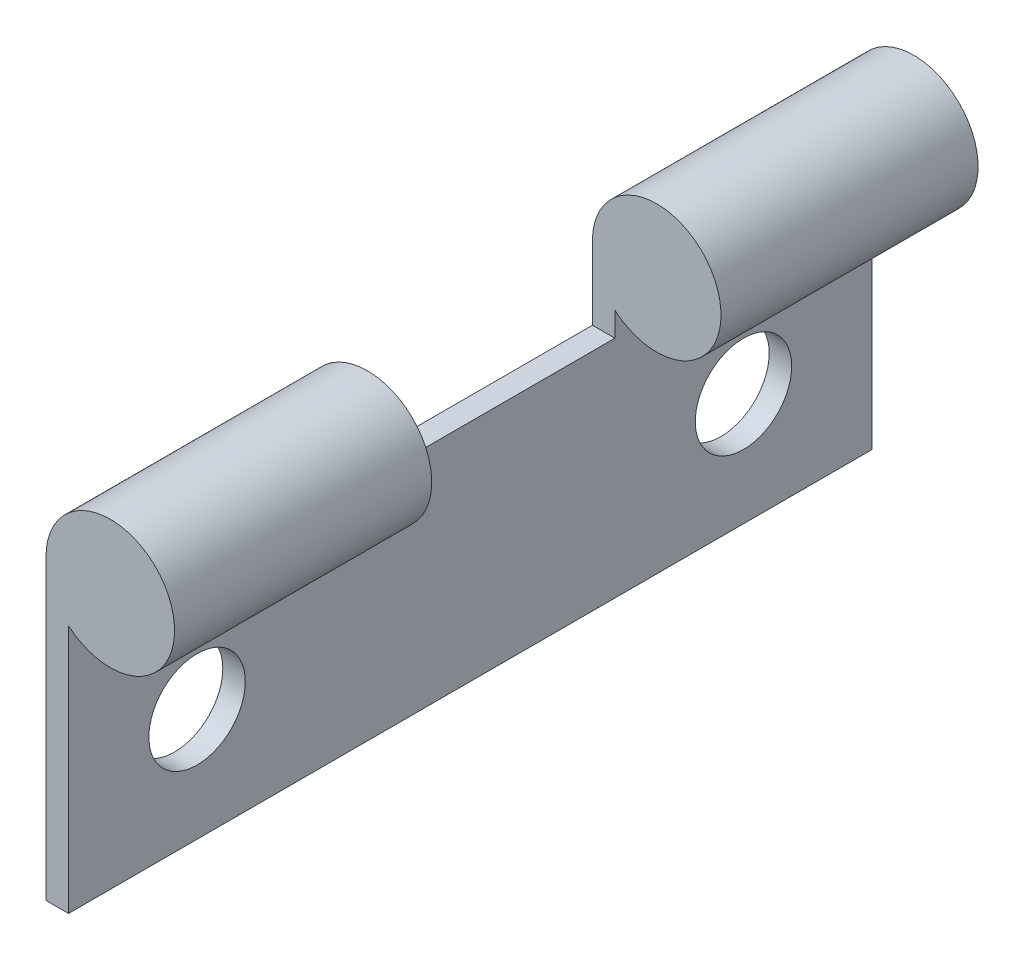
from build123d import *

# Parameters (mm, degrees)
SKETCH_1_R      = 1.5
EXTRUDE_1_DEPTH = 0.7
SKETCH_3_R      = 2
EXTRUDE_3_DEPTH = 8
SKETCH_4_R      = 2
EXTRUDE_4_DEPTH = 8


with BuildPart() as part:
    # 草图1 → 凸台-拉伸1 (new body)
    with BuildSketch(Plane(origin=(0, 0, 0), x_dir=(0, 0, -1), z_dir=(1, 0, 0))):
        Polygon((185.963773135, 67.574722086), (185.963773135, 60.574722086), (160.963773135, 60.574722086), (160.963773135, 67.574722086), (160.963773135, 69.848263268), (168.963773135, 69.848263268), (168.963773135, 67.574722086), (177.963773135, 67.574722086), (177.963773135, 69.848263268), (185.963773135, 69.848263268), align=None)
        with Locations((181.963773135, 64.074722086)):
            Circle(SKETCH_1_R, mode=Mode.SUBTRACT)
        with Locations((164.963773135, 64.074722086)):
            Circle(SKETCH_1_R, mode=Mode.SUBTRACT)
    extrude(amount=EXTRUDE_1_DEPTH)

    # 草图3 → 凸台-拉伸3 (add)
    with BuildSketch(Plane.XY.offset(-160.963773135)):
        with Locations((2, 69.848263268)):
            Circle(SKETCH_3_R)
    extrude(amount=-EXTRUDE_3_DEPTH)

    # 草图4 → 凸台-拉伸4 (add)
    with BuildSketch(Plane(origin=(0, 0, -185.963773135), x_dir=(-1, 0, 0), z_dir=(0, 0, -1))):
        with Locations((-2, 69.848263268)):
            Circle(SKETCH_4_R)
    extrude(amount=-EXTRUDE_4_DEPTH)


solid = part.part
